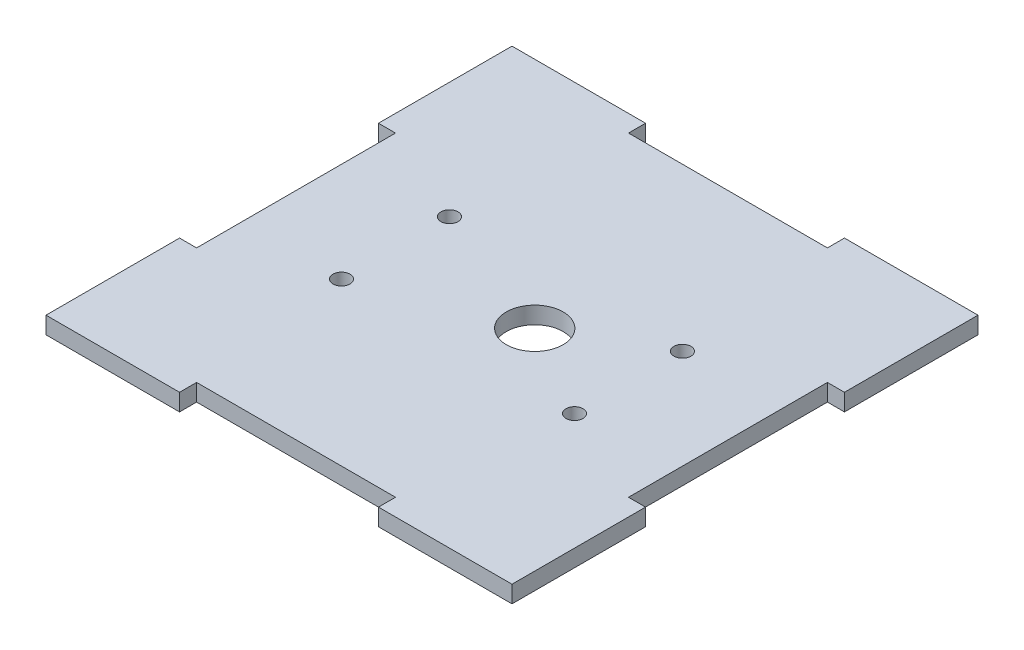
from build123d import *

# Parameters (mm, degrees)
BOSS_EXTRUDE1_DEPTH = 3
SKETCH2_R           = 5
SKETCH2_R_2         = 1.5
CUT_EXTRUDE1_DEPTH  = 3


with BuildPart() as part:
    # Sketch1 → Boss-Extrude1 (new body)
    with BuildSketch(Plane(origin=(0, 0, 0), x_dir=(1, 0, 0), z_dir=(0, 1, 0))):
        Polygon((-41, -41), (-17.5, -41), (-17.5, -38), (17.5, -38), (17.5, -41), (41, -41), (41, -17.5), (38, -17.5), (38, 17.5), (41, 17.5), (41, 41), (17.5, 41), (17.5, 38), (-17.5, 38), (-17.5, 41), (-41, 41), (-41, 17.5), (-38, 17.5), (-38, -17.5), (-41, -17.5), align=None)
    extrude(amount=BOSS_EXTRUDE1_DEPTH)

    # Sketch2 → Cut-Extrude1 (cut)
    with BuildSketch(Plane(origin=(0, 3, 0), x_dir=(1, 0, 0), z_dir=(0, 1, 0))):
        with Locations((4, 0)):
            Circle(SKETCH2_R)
        with Locations((-20.5, 9.5)):
            Circle(SKETCH2_R_2)
        with Locations((-20.5, -9.5)):
            Circle(SKETCH2_R_2)
        with Locations((20.5, -9.5)):
            Circle(SKETCH2_R_2)
        with Locations((20.5, 9.5)):
            Circle(SKETCH2_R_2)
    extrude(amount=-CUT_EXTRUDE1_DEPTH, mode=Mode.SUBTRACT)


solid = part.part
